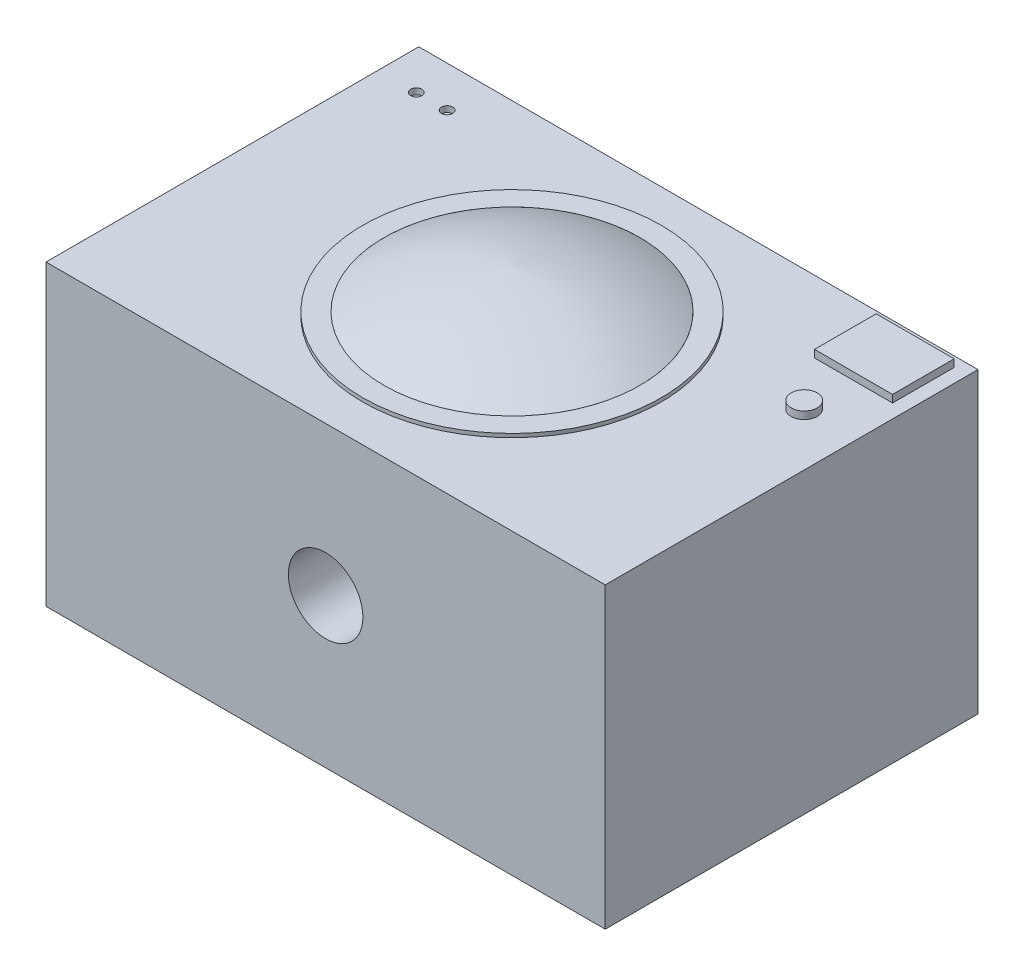
from build123d import *

# Parameters (mm, degrees)
SKETCH1_W           = 75
SKETCH1_H           = 50
BOSS_EXTRUDE1_DEPTH = 40
SKETCH2_R           = 20.026579708
SKETCH2_R_2         = 17.167030979
BOSS_EXTRUDE2_DEPTH = 0.5
SKETCH4_W           = 10.463265873
SKETCH4_H           = 8.273279993
SKETCH4_R           = 1.75
BOSS_EXTRUDE3_DEPTH = 1
SKETCH4_3_R         = 0.75
CUT_EXTRUDE1_DEPTH  = 0.8
SKETCH5_W           = 69.10457532
SKETCH5_H           = 31.591550446
CUT_EXTRUDE2_DEPTH  = 0.3
SKETCH6_W           = 73.486192876
SKETCH6_H           = 0.973327058
SKETCH6_W_2         = 18.930250774
SKETCH6_H_2         = 8.003422479
CUT_EXTRUDE3_DEPTH  = 0.3
SKETCH7_W           = 47.141566681
SKETCH7_H           = 12.456105017
CUT_EXTRUDE4_DEPTH  = 0.3
SKETCH8_R           = 5
CUT_EXTRUDE5_DEPTH  = 10


with BuildPart() as part:
    # Sketch1 → Boss-Extrude1 (new body)
    with BuildSketch(Plane(origin=(0, 0, 0), x_dir=(1, 0, 0), z_dir=(0, 1, 0))):
        Rectangle(SKETCH1_W, SKETCH1_H)
    extrude(amount=BOSS_EXTRUDE1_DEPTH)

    # Sketch2 → Boss-Extrude2 (add)
    with BuildSketch(Plane(origin=(0, 40, 0), x_dir=(1, 0, 0), z_dir=(0, 1, 0))):
        Circle(SKETCH2_R)
        Circle(SKETCH2_R_2, mode=Mode.SUBTRACT)
    extrude(amount=BOSS_EXTRUDE2_DEPTH)

    # Sketch4 → Boss-Extrude3 (add)
    with BuildSketch(Plane(origin=(0, 40, 0), x_dir=(1, 0, 0), z_dir=(0, 1, 0))):
        with Locations((30.416470562, 19.527374101)):
            Rectangle(SKETCH4_W, SKETCH4_H)
        with Locations((30.416470562, 8.774257155)):
            Circle(SKETCH4_R)
    extrude(amount=BOSS_EXTRUDE3_DEPTH)

    # Sketch4_3 → Cut-Extrude1 (cut)
    with BuildSketch(Plane(origin=(0, 40, 0), x_dir=(1, 0, 0), z_dir=(0, 1, 0))):
        with Locations((-32.363124677, 19.5273741)):
            Circle(SKETCH4_3_R)
        with Locations((-28.226484681, 19.5273741)):
            Circle(SKETCH4_3_R)
    extrude(amount=-CUT_EXTRUDE1_DEPTH, mode=Mode.SUBTRACT)

    # Sketch5 → Cut-Extrude2 (cut)
    with BuildSketch(Plane.XZ):
        Rectangle(SKETCH5_W, SKETCH5_H)
    extrude(amount=-CUT_EXTRUDE2_DEPTH, mode=Mode.SUBTRACT)

    # Sketch6 → Cut-Extrude3 (cut)
    with BuildSketch(Plane(origin=(0, 0, -25), x_dir=(-1, 0, 0), z_dir=(0, 0, -1))):
        with Locations((0, 5.726572375)):
            Rectangle(SKETCH6_W, SKETCH6_H)
        with Locations((-24.815596859, 10.934473399)):
            Rectangle(SKETCH6_W_2, SKETCH6_H_2)
    extrude(amount=-CUT_EXTRUDE3_DEPTH, mode=Mode.SUBTRACT)

    # Sketch7 → Cut-Extrude4 (cut)
    with BuildSketch(Plane.ZY.offset(37.5)):
        with Locations((-0.095816193, 19.227521614)):
            Rectangle(SKETCH7_W, SKETCH7_H)
    extrude(amount=-CUT_EXTRUDE4_DEPTH, mode=Mode.SUBTRACT)

    # Sketch8 → Cut-Extrude5 (cut)
    with BuildSketch(Plane.XY.offset(25)):
        with Locations((0, 20)):
            Circle(SKETCH8_R)
    extrude(amount=-CUT_EXTRUDE5_DEPTH, mode=Mode.SUBTRACT)


with BuildPart() as body_2:
    # Sketch3 → Revolve1 (revolve)
    with BuildSketch(Plane.XY):
        with BuildLine():
            Line((0, 40), (0, 45.641257661))
            ThreePointArc((0, 45.641257661), (8.873719043, 44.039639472), (17.167030979, 40.5))
            Line((17.167030979, 40.5), (0, 40))
        make_face()
    revolve(axis=Axis((0, 40, 0), (0, 1, 0)))


solid = Compound([part.part, body_2.part])
